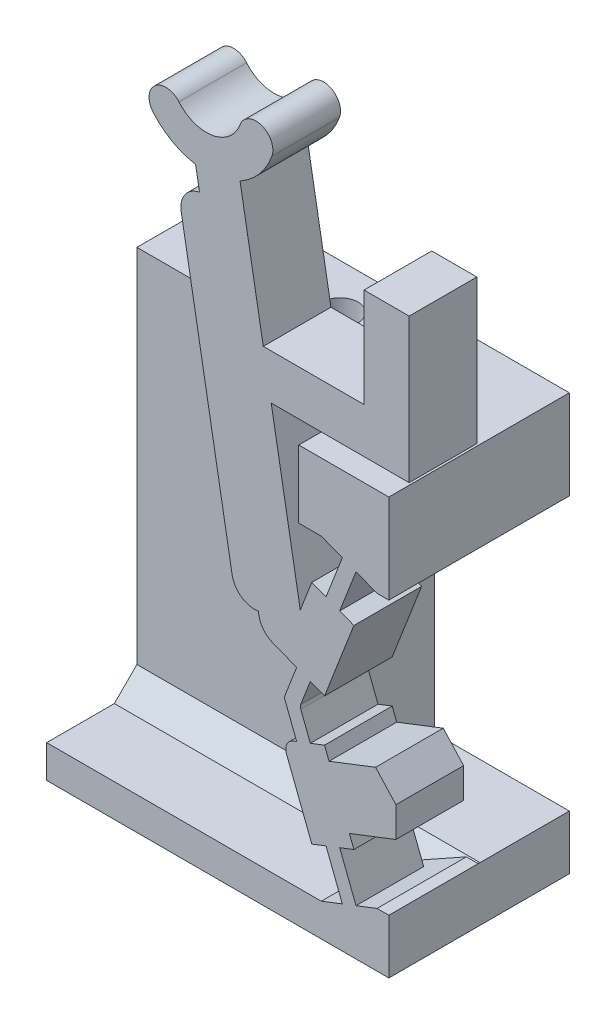
from build123d import *

# Parameters (mm, degrees)
BOSS_SWITCH_BODY_DEPTH            = 3
SKETCH1_W                         = 2.994375291
SKETCH1_H                         = 2.409101515
SKETCH1_W_2                       = 3.994375291
SKETCH1_H_2                       = 3.957767538
BOSS_FLANGE_WIDTH_DEPTH           = 5
BOSS_FLANGE_HEIGHT_REACH          = 36.354
SKETCH2_W                         = 4
SKETCH2_H                         = 3.957767538
SKETCH2_W_2                       = 8
SKETCH2_H_2                       = 1.451333978
SKETCH17_W                        = 15.1675
SKETCH17_H                        = 4
BOSS_FLANGE_SUPPORT_DEPTH         = 13.053634428
CUT_WALL_GAP_DEPTH                = 1
TAP_DRILL_FOR_M2X0_4_TAP1_D       = 1.6
M2_CLEARANCE_HOLE2_D              = 2.4
M2_CLEARANCE_HOLE2_DEPTH          = 13.462735941
CHAMFER_FLANGE_SUPPORT_3_SIZE     = 1
FILLET1_R                         = 1
FILLET2_R                         = 0.5
SKETCH28_W                        = 5.9675
SKETCH28_H                        = 12.095866891
CUT_PRINT_SUPPORT_CLEARANCE_DEPTH = 33.624103931


with BuildPart() as part:
    # Sketch-SwitchBossUp → Boss-Switch Body (new body)
    with BuildSketch(Plane.XY):
        with BuildLine():
            Line((-5.697895702, 26.949658376), (-5.524247524, 25.964850623))
            ThreePointArc((-5.524247524, 25.964850623), (-6.169751391, 25.553619307), (-6.3354071, 24.806394693))
            Line((-6.3354071, 24.806394693), (-4.07798079, 12.003893904))
            ThreePointArc((-4.07798079, 12.003893904), (-3.666749473, 11.358390037), (-2.919524859, 11.192734328))
            Line((-2.919524859, 11.192734328), (-2.795819507, 10.49116641))
            Line((-2.795819507, 10.49116641), (-1.8481327, 10.123820116))
            Line((-1.8481327, 10.123820116), (-1.21876104, 9.87986046))
            Line((-1.21876104, 9.87986046), (-1.735258621, 8.547390389))
            ThreePointArc((-1.735258621, 8.547390389), (-1.752158006, 8.457034961), (-1.735258621, 8.366679532))
            Line((-1.735258621, 8.366679532), (-1.21876104, 7.034209461))
            Line((-1.21876104, 7.034209461), (-1.8481327, 6.790249805))
            Line((-1.8481327, 6.790249805), (-0.547014535, 3.433600952))
            Line((-0.547014535, 3.433600952), (0.082357125, 3.677560608))
            Line((0.082357125, 3.677560608), (0.805200549, 1.81275569))
            Line((0.805200549, 1.81275569), (-0.12720191, 1.451333978))
            Line((-0.12720191, 1.451333978), (-0.12720191, 0))
            Line((-0.12720191, 0), (2.867173381, 0))
            Line((2.867173381, 0), (2.867173381, 2.409101515))
            Line((2.867173381, 2.409101515), (2.343664607, 2.409101515))
            Line((2.343664607, 2.409101515), (1.411262148, 2.047679803))
            Line((1.411262148, 2.047679803), (0.688418723, 3.912484721))
            Line((0.688418723, 3.912484721), (1.317790383, 4.156444377))
            Line((1.317790383, 4.156444377), (1.117265944, 4.673761056))
            Line((1.117265944, 4.673761056), (3.17940291, 5.473095148))
            Line((3.17940291, 5.473095148), (3.17940291, 6.808547192))
            Line((3.17940291, 6.808547192), (2.279218661, 7.795066081))
            Line((2.279218661, 7.795066081), (0.217196658, 6.995776551))
            Line((0.217196658, 6.995776551), (0.016672219, 7.51309323))
            Line((0.016672219, 7.51309323), (-0.612699441, 7.269133574))
            Line((-0.612699441, 7.269133574), (-1.038134762, 8.366679532))
            ThreePointArc((-1.038134762, 8.366679532), (-1.055034148, 8.457034961), (-1.038134762, 8.547390389))
            Line((-1.038134762, 8.547390389), (-0.612699441, 9.644936347))
            Line((-0.612699441, 9.644936347), (0.016672219, 9.400976691))
            Line((0.016672219, 9.400976691), (1.317790383, 12.757625544))
            Line((1.317790383, 12.757625544), (0.688418723, 13.0015852))
            Line((0.688418723, 13.0015852), (1.411262148, 14.866390118))
            Line((1.411262148, 14.866390118), (2.343664607, 14.504968406))
            Line((2.343664607, 14.504968406), (2.867173381, 14.504968406))
            Line((2.867173381, 14.504968406), (2.867173381, 18.462735944))
            Line((2.867173381, 18.462735944), (-0.111637615, 18.462735944))
            Line((-0.111637615, 18.462735944), (-1.12720191, 18.462735944))
            Line((-1.12720191, 18.462735944), (-1.12720191, 15.462735944))
            Line((-1.12720191, 15.462735944), (-0.12720191, 15.462735944))
            Line((-0.12720191, 15.462735944), (0.805200549, 15.101314231))
            Line((0.805200549, 15.101314231), (0.082357125, 13.236509313))
            Line((0.082357125, 13.236509313), (-0.547014535, 13.480468969))
            Line((-0.547014535, 13.480468969), (-1.059112089, 12.159350171))
            Line((-1.059112089, 12.159350171), (-2.346896051, 19.462735944))
            Line((-2.346896051, 19.462735944), (3.767173381, 19.462735944))
            Line((3.767173381, 19.462735944), (3.767173381, 25.857619356))
            Line((3.767173381, 25.857619356), (1.767173381, 25.857619356))
            Line((1.767173381, 25.857619356), (1.767173381, 21.462735944))
            Line((1.767173381, 21.462735944), (-2.699550012, 21.462735944))
            Line((-2.699550012, 21.462735944), (-3.728280196, 27.296954732))
            ThreePointArc((-3.728280196, 27.296954732), (-2.874356585, 27.992742953), (-2.319025652, 28.944012807))
            ThreePointArc((-2.319025652, 28.944012807), (-2.76728001, 29.905297381), (-3.728564583, 29.457043022))
            ThreePointArc((-3.728564583, 29.457043022), (-4.944660137, 28.436617692), (-6.436422172, 28.97957467))
            ThreePointArc((-6.436422172, 28.97957467), (-7.493046212, 29.072017295), (-7.585488837, 28.015393255))
            ThreePointArc((-7.585488837, 28.015393255), (-6.738295005, 27.311426358), (-5.697895702, 26.949658376))
        make_face()
    extrude(amount=BOSS_SWITCH_BODY_DEPTH)

    # Sketch1 → Boss-Flange Width (add)
    with BuildSketch(Plane(origin=(0, 0, 0), x_dir=(-1, 0, 0), z_dir=(0, 0, -1))):
        with Locations((-1.369985736, 1.204550758)):
            Rectangle(SKETCH1_W, SKETCH1_H)
        with Locations((-0.869985736, 16.483852175)):
            Rectangle(SKETCH1_W_2, SKETCH1_H_2)
    extrude(amount=BOSS_FLANGE_WIDTH_DEPTH)

    # Boss-Flange Height: up to this face of the body (flat: up to its plane)
    boss_flange_height_end = Plane(part.part.faces().sort_by_distance((-0.12720191, 1.077409098, -1.438016547))[0])
    # Sketch2 → Boss-Flange Height (add, up to the picked face)
    with BuildSketch(Plane(origin=(-12.300326619, 0, 0), x_dir=(0, 0, -1), z_dir=(1, 0, 0)), mode=Mode.PRIVATE) as boss_flange_height_sk1:
        with Locations((3, 16.483852175)):
            Rectangle(SKETCH2_W, SKETCH2_H)
    boss_flange_height_tool1 = split(extrude(boss_flange_height_sk1.sketch, amount=BOSS_FLANGE_HEIGHT_REACH, mode=Mode.PRIVATE), bisect_by=boss_flange_height_end, keep=Keep.BOTH, mode=Mode.PRIVATE)
    # Sketch2 → Boss-Flange Height (add, up to the picked face)
    with BuildSketch(Plane(origin=(-12.300326619, 0, 0), x_dir=(0, 0, -1), z_dir=(1, 0, 0)), mode=Mode.PRIVATE) as boss_flange_height_sk2:
        with Locations((1, 0.725666989)):
            Rectangle(SKETCH2_W_2, SKETCH2_H_2)
    boss_flange_height_tool2 = split(extrude(boss_flange_height_sk2.sketch, amount=BOSS_FLANGE_HEIGHT_REACH, mode=Mode.PRIVATE), bisect_by=boss_flange_height_end, keep=Keep.BOTH, mode=Mode.PRIVATE)
    add(boss_flange_height_tool1.solids().sort_by(Axis((-12.300327, 16.483852, -3), (1, 0, 0)))[0])
    add(boss_flange_height_tool2.solids().sort_by(Axis((-12.300327, 0.725667, -1), (1, 0, 0)))[0])

    # Sketch17 → Boss-Flange Support (add)
    with BuildSketch(Plane.XZ.offset(-1.451333978)):
        with Locations((-4.716576619, -3)):
            Rectangle(SKETCH17_W, SKETCH17_H)
    extrude(amount=-BOSS_FLANGE_SUPPORT_DEPTH)

    # Sketch27 → Cut-Wall Gap (cut)
    with BuildSketch(Plane.XY):
        Polygon((-0.12720191, 15.462735944), (2.343664607, 14.504968406), (-1.12720191, 14.504968406), (-1.12720191, 15.462735944), align=None)
        Polygon((2.343664607, 2.409101515), (-0.12720191, 2.409101515), (-0.12720191, 1.451333978), align=None)
    extrude(amount=-CUT_WALL_GAP_DEPTH, mode=Mode.SUBTRACT)

    # Tap Drill for M2x0.4 Tap1 (through all)
    with Locations(Plane(origin=(0, 0, 0), x_dir=(-1, 0, 0), z_dir=(0, -1, 0))):
        with Locations((9.300326619, 3), (5.300326619, 3)):
            Hole(TAP_DRILL_FOR_M2X0_4_TAP1_D / 2)

    # M2 Clearance Hole2
    with Locations(Plane.XZ):
        with Locations((-9.300326619, -3), (-5.300326619, -3)):
            Hole(M2_CLEARANCE_HOLE2_D / 2, depth=M2_CLEARANCE_HOLE2_DEPTH)

    # Chamfer-Flange Support 3
    chamfer_flange_support_3_edges = [part.edges().sort_by_distance(p)[0] for p in [
        (-6.213764264, 1.451333978, -1),
    ]]
    chamfer(chamfer_flange_support_3_edges, length=CHAMFER_FLANGE_SUPPORT_3_SIZE)

    # Fillet1
    fillet1_edges = [part.edges().sort_by_distance(p)[0] for p in [
        (-2.795819507, 10.49116641, 1.5),
    ]]
    fillet(fillet1_edges, radius=FILLET1_R)

    # Fillet2
    fillet2_edges = [part.edges().sort_by_distance(p)[0] for p in [
        (-1.8481327, 6.790249805, 1.5),
    ]]
    fillet(fillet2_edges, radius=FILLET2_R)

    # Sketch28 → Cut-Print Support Clearance (cut, through all)
    with BuildSketch(Plane.XY.offset(-1)):
        with Locations((-0.116576619, 8.457034961)):
            Rectangle(SKETCH28_W, SKETCH28_H)
    extrude(amount=-CUT_PRINT_SUPPORT_CLEARANCE_DEPTH, mode=Mode.SUBTRACT)


solid = part.part
